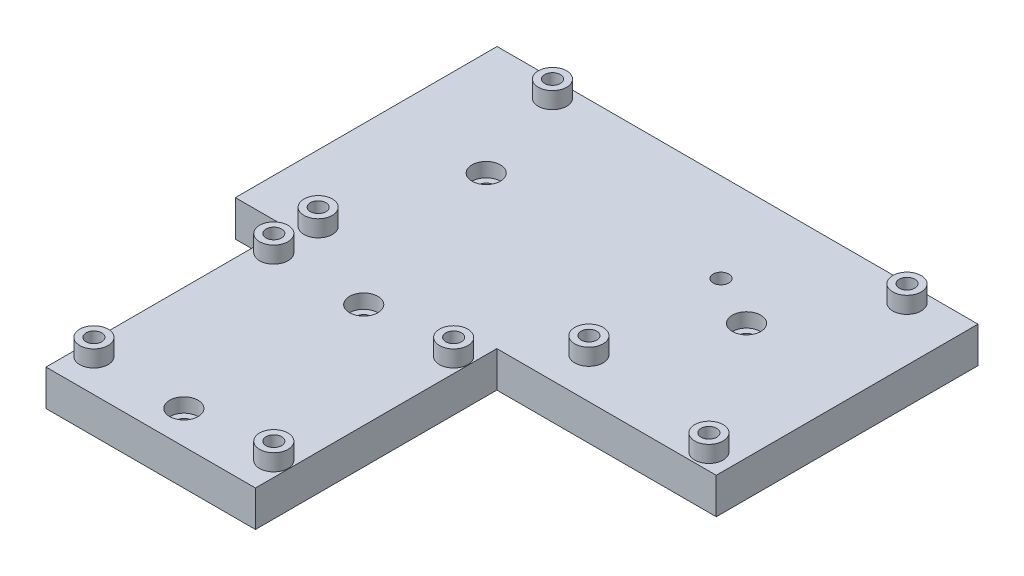
from build123d import *

# Parameters (mm, degrees)
SKETCH1_W           = 11
SKETCH1_H           = 1
SKETCH1_W_2         = 101.6
SKETCH1_W_3         = 46.35
SKETCH1_R           = 1.65
BOSS_EXTRUDE1_DEPTH = 7.6
SKETCH2_R           = 3
CUT_EXTRUDE1_DEPTH  = 3
SKETCH3_R           = 3
SKETCH3_R_2         = 1.65
BOSS_EXTRUDE3_DEPTH = 3.5


with BuildPart() as part:
    # Sketch1 → Boss-Extrude1 (new body)
    with BuildSketch(Plane(origin=(0, 0, 0), x_dir=(1, 0, 0), z_dir=(0, 1, 0))):
        with Locations((-5.5, 51.5)):
            Rectangle(SKETCH1_W, SKETCH1_H)
        with Locations((39.8, 105.8)):
            Rectangle(SKETCH1_W_2, SKETCH1_H)
        with Locations((67.425, 51.5)):
            Rectangle(SKETCH1_W_3, SKETCH1_H)
        Polygon((-11, 52), (-11, 105.3), (90.6, 105.3), (90.6, 52), (44.25, 52), (44.25, 0), (0, 0), (0, 52), align=None)
        with Locations((22.125, 7)):
            Circle(SKETCH1_R, mode=Mode.SUBTRACT)
        with Locations((22.125, 45)):
            Circle(SKETCH1_R, mode=Mode.SUBTRACT)
        with Locations((66, 82)):
            Circle(SKETCH1_R, mode=Mode.SUBTRACT)
        with Locations((11, 82)):
            Circle(SKETCH1_R, mode=Mode.SUBTRACT)
        with Locations((41.125, 7)):
            Circle(SKETCH1_R, mode=Mode.SUBTRACT)
        with Locations((3.125, 7)):
            Circle(SKETCH1_R, mode=Mode.SUBTRACT)
        with Locations((41.125, 45)):
            Circle(SKETCH1_R, mode=Mode.SUBTRACT)
        with Locations((3.125, 45)):
            Circle(SKETCH1_R, mode=Mode.SUBTRACT)
        with Locations((85.55, 54.5)):
            Circle(SKETCH1_R, mode=Mode.SUBTRACT)
        with Locations((55.1, 59.6)):
            Circle(SKETCH1_R, mode=Mode.SUBTRACT)
        with Locations((55.1, 87.5)):
            Circle(SKETCH1_R, mode=Mode.SUBTRACT)
        with Locations((3, 54.5)):
            Circle(SKETCH1_R, mode=Mode.SUBTRACT)
        with Locations((79.2, 102.7)):
            Circle(SKETCH1_R, mode=Mode.SUBTRACT)
        with Locations((4.3, 102.7)):
            Circle(SKETCH1_R, mode=Mode.SUBTRACT)
    extrude(amount=BOSS_EXTRUDE1_DEPTH)

    # Sketch2 → Cut-Extrude1 (cut)
    with BuildSketch(Plane(origin=(0, 7.6, 0), x_dir=(1, 0, 0), z_dir=(0, 1, 0))):
        with Locations((11, 82)):
            Circle(SKETCH2_R)
        with Locations((66, 82)):
            Circle(SKETCH2_R)
        with Locations((22.125, 45)):
            Circle(SKETCH2_R)
        with Locations((22.125, 7)):
            Circle(SKETCH2_R)
    extrude(amount=-CUT_EXTRUDE1_DEPTH, mode=Mode.SUBTRACT)

    # Sketch3 → Boss-Extrude3 (add)
    with BuildSketch(Plane(origin=(0, 7.6, 0), x_dir=(1, 0, 0), z_dir=(0, 1, 0))):
        with Locations((3.125, 7)):
            Circle(SKETCH3_R)
        with Locations((3.125, 7)):
            Circle(SKETCH3_R_2, mode=Mode.SUBTRACT)
        with Locations((41.125, 7)):
            Circle(SKETCH3_R)
        with Locations((41.125, 7)):
            Circle(SKETCH3_R_2, mode=Mode.SUBTRACT)
        with Locations((3.125, 45)):
            Circle(SKETCH3_R)
        with Locations((3.125, 45)):
            Circle(SKETCH3_R_2, mode=Mode.SUBTRACT)
        with Locations((41.125, 45)):
            Circle(SKETCH3_R)
        with Locations((41.125, 45)):
            Circle(SKETCH3_R_2, mode=Mode.SUBTRACT)
        with Locations((3, 54.5)):
            Circle(SKETCH3_R)
        with Locations((3, 54.5)):
            Circle(SKETCH3_R_2, mode=Mode.SUBTRACT)
        with Locations((55.1, 59.6)):
            Circle(SKETCH3_R)
        with Locations((55.1, 59.6)):
            Circle(SKETCH3_R_2, mode=Mode.SUBTRACT)
        with Locations((85.55, 54.5)):
            Circle(SKETCH3_R)
        with Locations((85.55, 54.5)):
            Circle(SKETCH3_R_2, mode=Mode.SUBTRACT)
        with Locations((79.2, 102.7)):
            Circle(SKETCH3_R)
        with Locations((79.2, 102.7)):
            Circle(SKETCH3_R_2, mode=Mode.SUBTRACT)
        with Locations((4.3, 102.7)):
            Circle(SKETCH3_R)
        with Locations((4.3, 102.7)):
            Circle(SKETCH3_R_2, mode=Mode.SUBTRACT)
    extrude(amount=BOSS_EXTRUDE3_DEPTH)


solid = part.part
